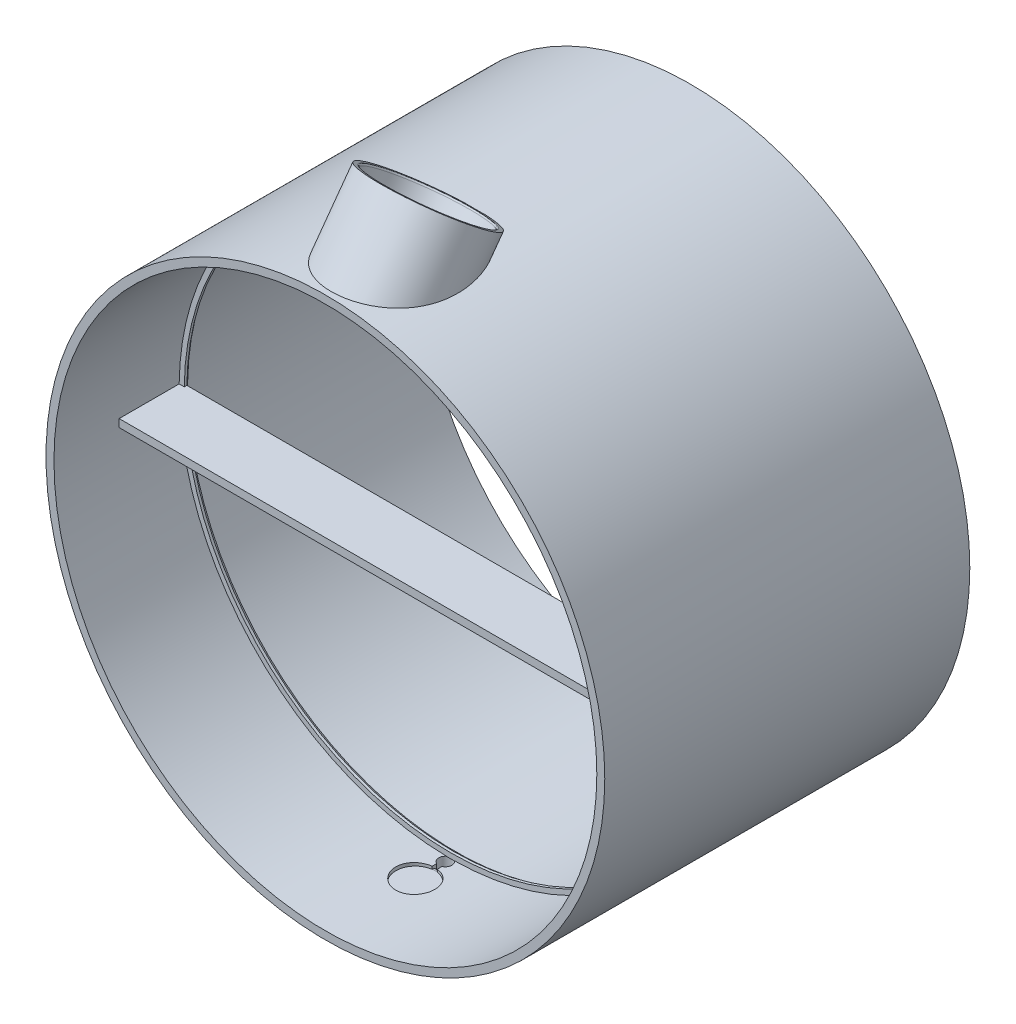
from build123d import *

# Parameters (mm, degrees)
BOSS_EXTRUDE2_DEPTH      = 70
BOSS_EXTRUDE2_DEPTH_BACK = 70
SKETCH2_R                = 107.15
SKETCH10_R               = 19
CUT_EXTRUDE2_DEPTH       = 10
BOSS_EXTRUDE6_DEPTH      = 32
BOSS_EXTRUDE6_DEPTH_BACK = 1
SKETCH18_R               = 22.5
BOSS_EXTRUDE7_DEPTH      = 5
BOSS_EXTRUDE7_DEPTH_BACK = 6
SKETCH56_R               = 30.95
SKETCH20_R               = 104.1
CUT_EXTRUDE3_DEPTH       = 140
CUT_EXTRUDE14_DEPTH      = 5
CUT_EXTRUDE14_DEPTH_BACK = 55
SKETCH51_R               = 2.5
CUT_EXTRUDE15_DEPTH      = 5
SKETCH44_R               = 7.5
CUT_EXTRUDE10_DEPTH      = 10
FILLET3_R                = 1.5
SKETCH61_R               = 104.15
BOSS_EXTRUDE8_DEPTH      = 2
SKETCH62_R               = 102.15
CUT_EXTRUDE16_DEPTH      = 10
CHAMFER7_SIZE            = 1
CHAMFER7_SIZE2           = 0.700207538
SKETCH5_W                = 211.3
SKETCH5_H                = 3
BOSS_EXTRUDE3_DEPTH      = 24
SKETCH24_R               = 18.25
CUT_EXTRUDE6_DEPTH       = 50
CUT_EXTRUDE5_DEPTH       = 7
CUT_EXTRUDE5_DEPTH_BACK  = 5
SKETCH23_R               = 20.45
CHAMFER1_SIZE            = 0.5
FILLET4_R                = 0.6
CUT_EXTRUDE19_DEPTH      = 4


with BuildPart() as part:
    # Sketch2 → Boss-Extrude2 (new, two sides: drawn at the far end of the back side and taken through both)
    with BuildSketch(Plane.XY.offset(-BOSS_EXTRUDE2_DEPTH_BACK)):
        Circle(SKETCH2_R)
    extrude(amount=BOSS_EXTRUDE2_DEPTH + BOSS_EXTRUDE2_DEPTH_BACK)

    # Sketch10 → Cut-Extrude2 (cut, symmetric)
    with BuildSketch(Plane(origin=(0, 51.109455148, -37.133192748), x_dir=(1, 0, 0), z_dir=(0, -0.8090169943749408, 0.5877852522924822))):
        with Locations((0, 95.341869558)):
            Circle(SKETCH10_R)
    extrude(amount=CUT_EXTRUDE2_DEPTH, both=True, mode=Mode.SUBTRACT)

    # Sketch18 → Boss-Extrude6 (add, two sides: drawn at the far end of the back side and taken through both)
    with BuildSketch(Plane(origin=(0, 63.244710063, -45.949971532), x_dir=(1, 0, 0), z_dir=(0, -0.8090169943749408, 0.5877852522924822)).offset(-BOSS_EXTRUDE6_DEPTH_BACK)):
        with Locations((0, 95.341869558)):
            Circle(SKETCH18_R)
    extrude(amount=BOSS_EXTRUDE6_DEPTH + BOSS_EXTRUDE6_DEPTH_BACK)

    # Sketch56 → Boss-Extrude7 (add, two sides: drawn at the far end of the back side and taken through both)
    with BuildSketch(Plane(origin=(0, -107.15, 0), x_dir=(1, 0, 0), z_dir=(0, 1, 0)).offset(-BOSS_EXTRUDE7_DEPTH_BACK)):
        with Locations((0, 1.5)):
            Circle(SKETCH56_R)
    extrude(amount=BOSS_EXTRUDE7_DEPTH + BOSS_EXTRUDE7_DEPTH_BACK)

    # Sketch20 → Cut-Extrude3 (cut)
    with BuildSketch(Plane.XY.offset(70)):
        Circle(SKETCH20_R)
    extrude(amount=-CUT_EXTRUDE3_DEPTH, mode=Mode.SUBTRACT)

    # Sketch51 → Cut-Extrude14 (cut, two sides: drawn at the far end of the back side and taken through both)
    with BuildSketch(Plane(origin=(0, -107.15, 0), x_dir=(1, 0, 0), z_dir=(0, 1, 0)).offset(-CUT_EXTRUDE14_DEPTH_BACK)):
        with Locations((0, -24)):
            Circle(SKETCH51_R)
    extrude(amount=CUT_EXTRUDE14_DEPTH + CUT_EXTRUDE14_DEPTH_BACK, mode=Mode.SUBTRACT)

    # Sketch58 → Cut-Extrude15 (cut)
    with BuildSketch(Plane(origin=(0, -105.15, 0), x_dir=(1, 0, 0), z_dir=(0, 1, 0))):
        Polygon((0, -24), (1, -24), (1, -34.192827208), (-1, -34.192827208), (-1, -24), align=None)
    extrude(amount=CUT_EXTRUDE15_DEPTH, mode=Mode.SUBTRACT)

    # Sketch44 → Cut-Extrude10 (cut)
    with BuildSketch(Plane(origin=(0, -105.15, 0), x_dir=(1, 0, 0), z_dir=(0, 1, 0))):
        with Locations((0, -35.5)):
            Circle(SKETCH44_R)
    extrude(amount=CUT_EXTRUDE10_DEPTH, mode=Mode.SUBTRACT)

    # Fillet3
    fillet3_edges = [part.edges().sort_by_distance(p)[0] for p in [
        (0, -105.15, 26.5),
    ]]
    fillet(fillet3_edges, radius=FILLET3_R)

    # Sketch61 → Boss-Extrude8 (add)
    with BuildSketch(Plane.XY.offset(22)):
        Circle(SKETCH61_R)
    extrude(amount=-BOSS_EXTRUDE8_DEPTH)

    # Sketch62 → Cut-Extrude16 (cut)
    with BuildSketch(Plane.XY.offset(22)):
        Circle(SKETCH62_R)
    extrude(amount=-CUT_EXTRUDE16_DEPTH, mode=Mode.SUBTRACT)

    # Chamfer7
    chamfer7_edges = [part.edges().sort_by_distance(p)[0] for p in [
        (-102.15, 0, 20),
    ]]
    chamfer7_side = [part.faces().sort_by_distance(p)[0] for p in [
        (-102.15, 0, 21),
    ]]
    chamfer(chamfer7_edges, length=CHAMFER7_SIZE, length2=CHAMFER7_SIZE2, reference=chamfer7_side[0])

    # Sketch5 → Boss-Extrude3 (add)
    with BuildSketch(Plane.XY.offset(45)):
        Rectangle(SKETCH5_W, SKETCH5_H)
    extrude(amount=-BOSS_EXTRUDE3_DEPTH)

    # Sketch24 → Cut-Extrude6 (cut)
    with BuildSketch(Plane(origin=(0, 63.244710063, -45.949971532), x_dir=(1, 0, 0), z_dir=(0, -0.8090169943749408, 0.5877852522924822))):
        with Locations((0, 95.341869558)):
            Circle(SKETCH24_R)
    extrude(amount=CUT_EXTRUDE6_DEPTH, mode=Mode.SUBTRACT)

    # Sketch23 → Cut-Extrude5 (cut, two sides: drawn at the far end of the back side and taken through both)
    with BuildSketch(Plane(origin=(0, 63.244710063, -45.949971532), x_dir=(1, 0, 0), z_dir=(0, -0.8090169943749408, 0.5877852522924822)).offset(-CUT_EXTRUDE5_DEPTH_BACK)):
        with Locations((0, 95.341869558)):
            Circle(SKETCH23_R)
    extrude(amount=CUT_EXTRUDE5_DEPTH + CUT_EXTRUDE5_DEPTH_BACK, mode=Mode.SUBTRACT)

    # Chamfer1
    chamfer1_edges = [part.edges().sort_by_distance(p)[0] for p in [
        (-30.95, -113.15, -1.5),
    ]]
    chamfer(chamfer1_edges, length=CHAMFER1_SIZE)

    # Fillet4
    fillet4_edges = [part.edges().sort_by_distance(p)[0] for p in [
        (-20.45, 120.09427191, 30.595435963),
    ]]
    fillet(fillet4_edges, radius=FILLET4_R)

    # Sketch67 → Cut-Extrude19 (cut)
    with BuildSketch(Plane(origin=(0, 57.581591103, -41.835474766), x_dir=(1, 0, 0), z_dir=(0, 0.8090169943749409, -0.5877852522924822))):
        Polygon((-7.872943576, -76.468097824), (7.872943576, -76.468097824), (7.872943576, -79.749667474), (-7.872943576, -79.48866005), align=None)
    extrude(amount=-CUT_EXTRUDE19_DEPTH, mode=Mode.SUBTRACT)


solid = part.part
